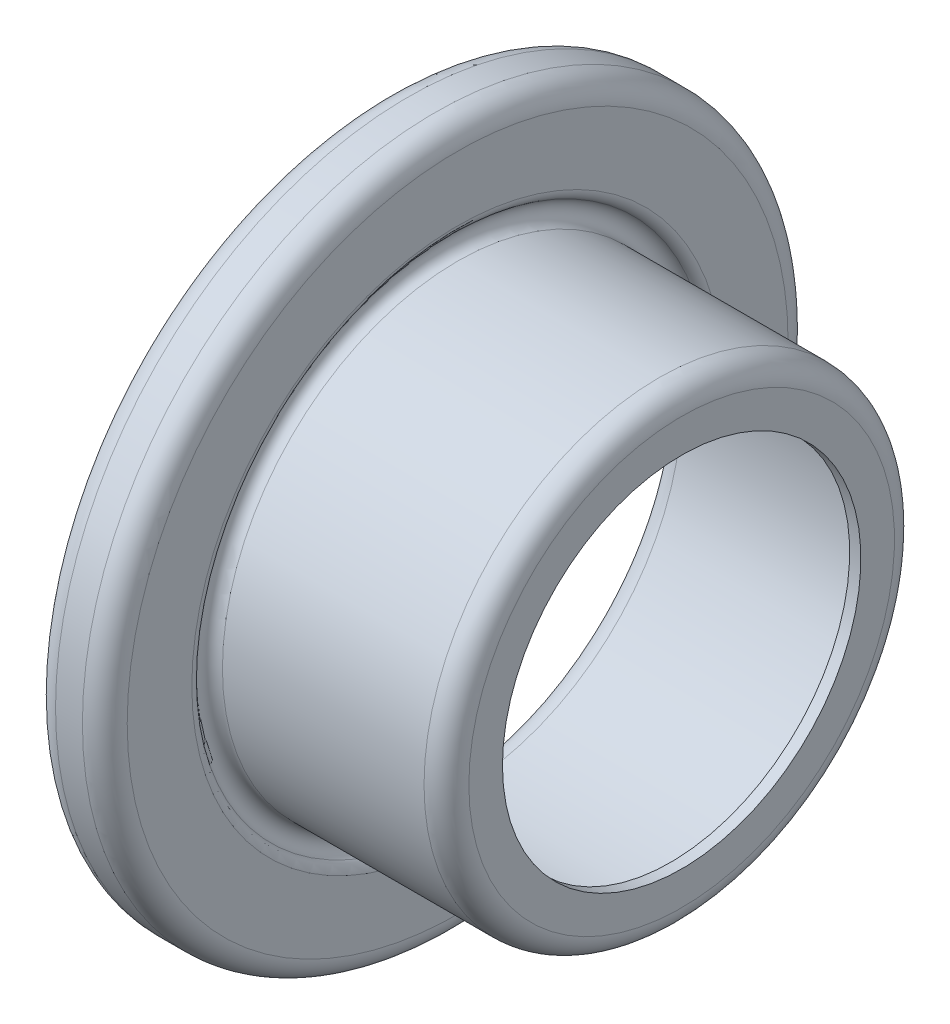
from build123d import *


with BuildPart() as part:
    # Esquisse1 → Base-Révol.-Mince (revolve)
    with BuildSketch(Plane.XY):
        with BuildLine():
            Line((0, 8), (0, 9.5))
            ThreePointArc((0, 9.5), (-0.292893219, 10.207106781), (-1, 10.5))
            Line((-1, 10.5), (-10, 10.5))
            ThreePointArc((-10, 10.5), (-10.482962913, 10.870590477), (-10.25, 11.433012702))
            ThreePointArc((-10.25, 11.433012702), (-10.066987298, 11.616025404), (-10, 11.866025404))
            Line((-10, 11.866025404), (-10, 14.75))
            ThreePointArc((-10, 14.75), (-10.292893219, 15.457106781), (-11, 15.75))
            Line((-11, 15.75), (-12.2, 15.75))
            ThreePointArc((-12.2, 15.75), (-12.907106781, 15.457106781), (-13.2, 14.75))
            Line((-13.2, 14.75), (-13.2, 14))
            Line((-13.2, 14), (-12.7, 14))
            Line((-12.7, 14), (-12.7, 14.75))
            ThreePointArc((-12.7, 14.75), (-12.553553391, 15.103553391), (-12.2, 15.25))
            Line((-12.2, 15.25), (-11, 15.25))
            ThreePointArc((-11, 15.25), (-10.646446609, 15.103553391), (-10.5, 14.75))
            Line((-10.5, 14.75), (-10.5, 11.866025404))
            ThreePointArc((-10.5, 11.866025404), (-10.965925826, 10.741180955), (-10, 10))
            Line((-10, 10), (-1, 10))
            ThreePointArc((-1, 10), (-0.646446609, 9.853553391), (-0.5, 9.5))
            Line((-0.5, 9.5), (-0.5, 8))
            Line((-0.5, 8), (0, 8))
        make_face()
    revolve(axis=Axis((-70, 0, 0), (1, 0, 0)))

    # Esquisse2 → Enlèvement de matière-Révolution1 (revolve, cut)
    with BuildSketch(Plane.XY):
        with BuildLine():
            Line((-12.9, 14), (-12.9, 14.75))
            ThreePointArc((-12.9, 14.75), (-12.753553391, 15.103553391), (-12.4, 15.25))
            Line((-12.4, 15.25), (-11, 15.25))
            Line((-11, 15.25), (-12.286824089, 15.023098194))
            ThreePointArc((-12.286824089, 15.023098194), (-12.583022222, 14.852088122), (-12.7, 14.530694317))
            Line((-12.7, 14.530694317), (-12.7, 14))
            Line((-12.7, 14), (-12.9, 14))
        make_face()
    revolve(axis=Axis((4.1, 0, 0), (-1, 0, 0)), mode=Mode.SUBTRACT)


solid = part.part
